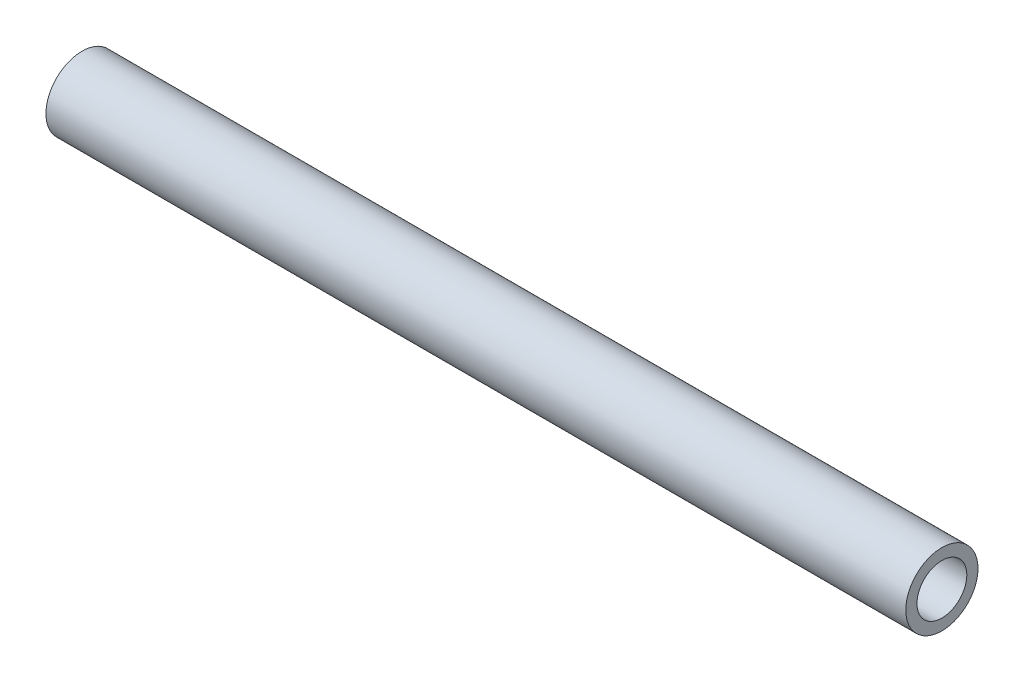
from build123d import *

# Parameters (mm, degrees)
SKETCH1_R           = 10.668
SKETCH1_R_2         = 7.366
BOSS_EXTRUDE1_DEPTH = 254


with BuildPart() as part:
    # Sketch1 → Boss-Extrude1 (new body)
    with BuildSketch(Plane(origin=(0, 0, 0), x_dir=(0, 0, -1), z_dir=(1, 0, 0))):
        Circle(SKETCH1_R)
        Circle(SKETCH1_R_2, mode=Mode.SUBTRACT)
    extrude(amount=-BOSS_EXTRUDE1_DEPTH)


solid = part.part
